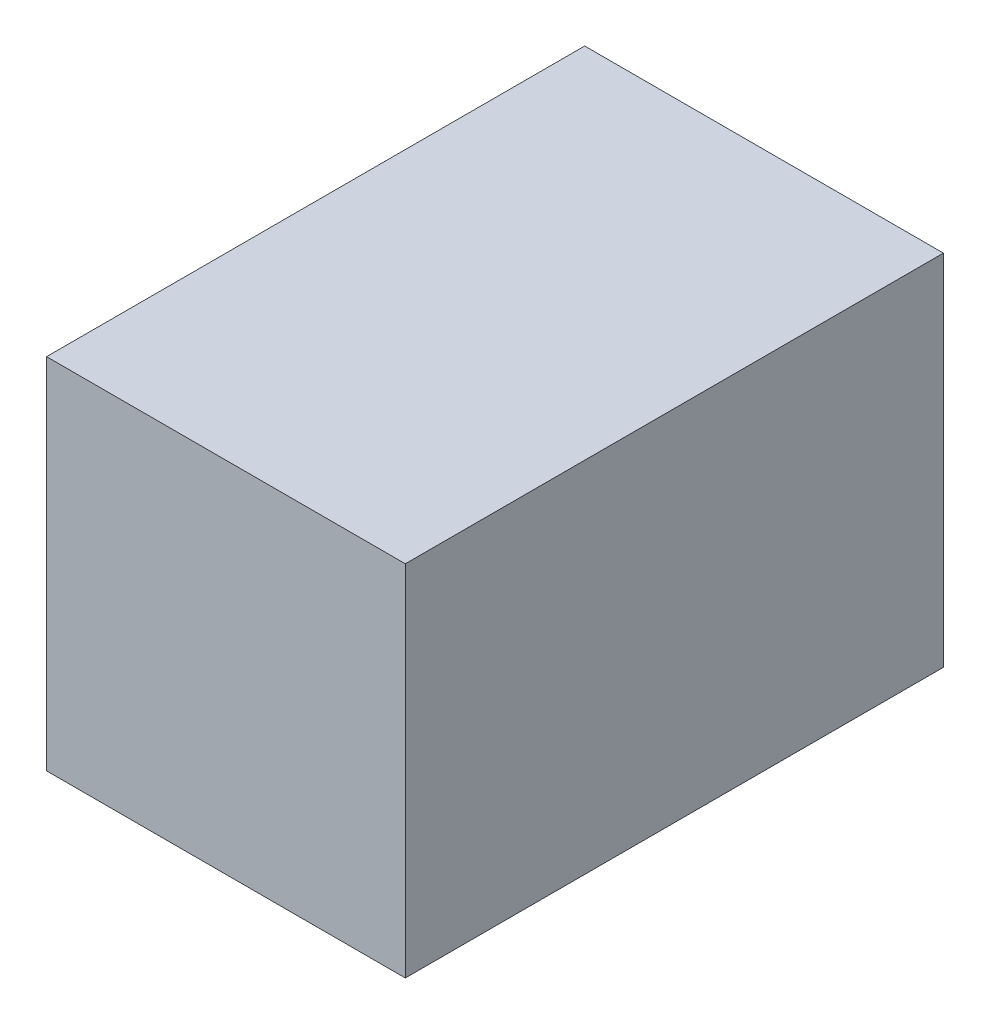
from build123d import *

# Parameters (mm, degrees)
SKETCH1_W           = 50
SKETCH1_H           = 50
BOSS_EXTRUDE1_DEPTH = 37.5


with BuildPart() as part:
    # Sketch1 → Boss-Extrude1 (new body, symmetric)
    with BuildSketch(Plane.XY):
        Rectangle(SKETCH1_W, SKETCH1_H)
    extrude(amount=BOSS_EXTRUDE1_DEPTH, both=True)


solid = part.part
